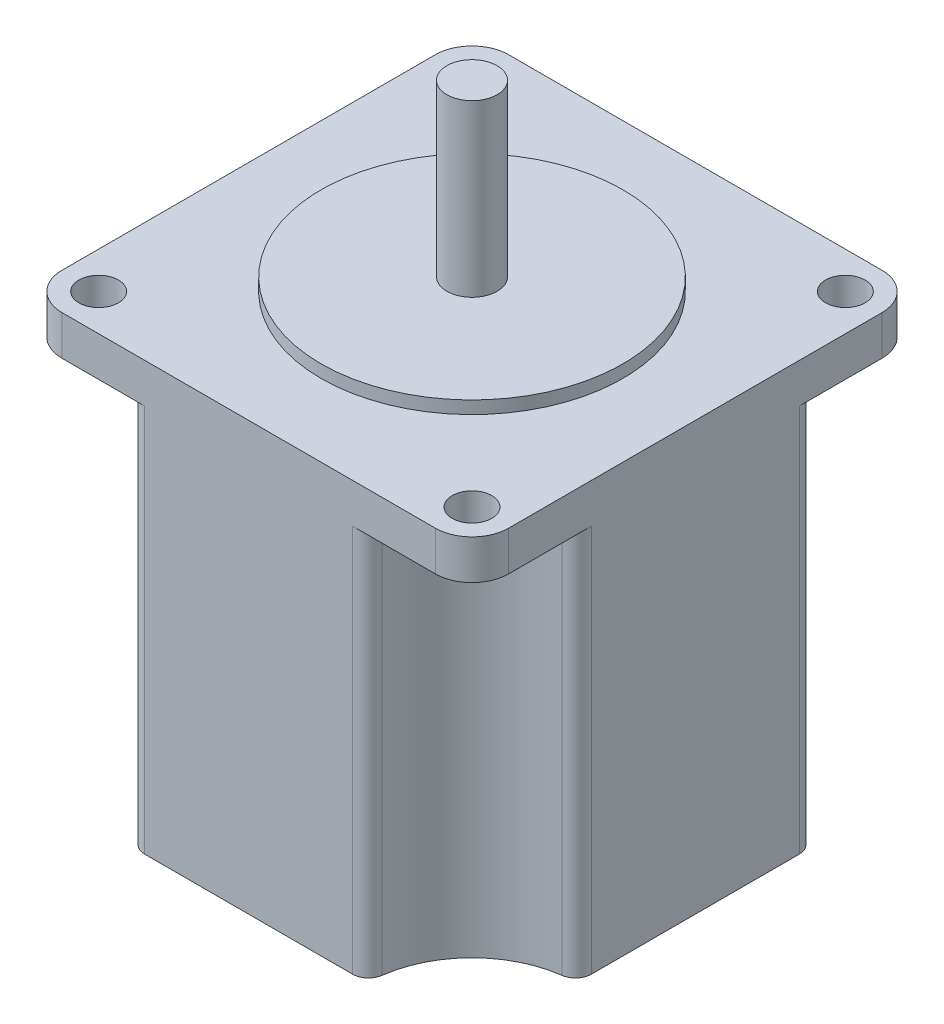
from build123d import *

# Parameters (mm, degrees)
BOSS_EXTRUDE1_DEPTH = 54
SKETCH2_R           = 2.5
CUT_EXTRUDE1_DEPTH  = 54
SKETCH3_OUTSIDE_W   = 77.664
SKETCH3_OUTSIDE_H   = 77.664
CUT_EXTRUDE3_DEPTH  = 49
SKETCH4_R           = 19.05
BOSS_EXTRUDE2_DEPTH = 1.6
SKETCH5_R           = 3.175
BOSS_EXTRUDE3_DEPTH = 21.5


with BuildPart() as part:
    # Sketch1 → Boss-Extrude1 (new body)
    with BuildSketch(Plane(origin=(0, 0, 0), x_dir=(1, 0, 0), z_dir=(0, 1, 0))):
        with BuildLine():
            Line((0, 51.77), (0, 4.63))
            ThreePointArc((0, 4.63), (1.356095603, 1.356095603), (4.63, 0))
            Line((4.63, 0), (51.77, 0))
            ThreePointArc((51.77, 0), (55.043904397, 1.356095603), (56.4, 4.63))
            Line((56.4, 4.63), (56.4, 51.77))
            ThreePointArc((56.4, 51.77), (55.043904397, 55.043904397), (51.77, 56.4))
            Line((51.77, 56.4), (4.63, 56.4))
            ThreePointArc((4.63, 56.4), (1.356095603, 55.043904397), (0, 51.77))
        make_face()
    extrude(amount=BOSS_EXTRUDE1_DEPTH)

    # Sketch2 → Cut-Extrude1 (cut)
    with BuildSketch(Plane(origin=(0, 54, 0), x_dir=(1, 0, 0), z_dir=(0, 1, 0))):
        with Locations((4.63, 51.77)):
            Circle(SKETCH2_R)
        with Locations((51.77, 51.77)):
            Circle(SKETCH2_R)
        with Locations((51.77, 4.63)):
            Circle(SKETCH2_R)
        with Locations((4.63, 4.63)):
            Circle(SKETCH2_R)
    extrude(amount=-CUT_EXTRUDE1_DEPTH, mode=Mode.SUBTRACT)

    # Sketch3 outside → Cut-Extrude3 (cut)
    with BuildSketch(Plane.XZ):
        with Locations((28.2, -28.2)):
            Rectangle(SKETCH3_OUTSIDE_W, SKETCH3_OUTSIDE_H)
        with BuildLine():
            Line((15.067846561, -56.4), (41.332153439, -56.4))
            ThreePointArc((41.332153439, -56.4), (42.650046494, -55.904379571), (43.314764828, -54.663157895))
            ThreePointArc((43.314764828, -54.663157895), (47.066190488, -47.066190488), (54.663157895, -43.314764828))
            ThreePointArc((54.663157895, -43.314764828), (55.904379571, -42.650046494), (56.4, -41.332153439))
            Line((56.4, -41.332153439), (56.4, -15.067846561))
            ThreePointArc((56.4, -15.067846561), (55.904379571, -13.749953506), (54.663157895, -13.085235172))
            ThreePointArc((54.663157895, -13.085235172), (47.066190488, -9.333809512), (43.314764828, -1.736842105))
            ThreePointArc((43.314764828, -1.736842105), (42.650046494, -0.495620429), (41.332153439, 0))
            Line((41.332153439, 0), (15.067846561, 0))
            ThreePointArc((15.067846561, 0), (13.749953506, -0.495620429), (13.085235172, -1.736842105))
            ThreePointArc((13.085235172, -1.736842105), (9.333809512, -9.333809512), (1.736842105, -13.085235172))
            ThreePointArc((1.736842105, -13.085235172), (0.495620429, -13.749953506), (0, -15.067846561))
            Line((0, -15.067846561), (0, -41.332153439))
            ThreePointArc((0, -41.332153439), (0.495620429, -42.650046494), (1.736842105, -43.314764828))
            ThreePointArc((1.736842105, -43.314764828), (9.333809512, -47.066190488), (13.085235172, -54.663157895))
            ThreePointArc((13.085235172, -54.663157895), (13.749953506, -55.904379571), (15.067846561, -56.4))
        make_face(mode=Mode.SUBTRACT)
    extrude(amount=-CUT_EXTRUDE3_DEPTH, mode=Mode.SUBTRACT)

    # Sketch4 → Boss-Extrude2 (add)
    with BuildSketch(Plane(origin=(0, 54, 0), x_dir=(1, 0, 0), z_dir=(0, 1, 0))):
        with Locations((28.2, 28.2)):
            Circle(SKETCH4_R)
    extrude(amount=BOSS_EXTRUDE2_DEPTH)

    # Sketch5 → Boss-Extrude3 (add)
    with BuildSketch(Plane(origin=(0, 55.6, 0), x_dir=(1, 0, 0), z_dir=(0, 1, 0))):
        with Locations((28.2, 28.2)):
            Circle(SKETCH5_R)
    extrude(amount=BOSS_EXTRUDE3_DEPTH)


solid = part.part
